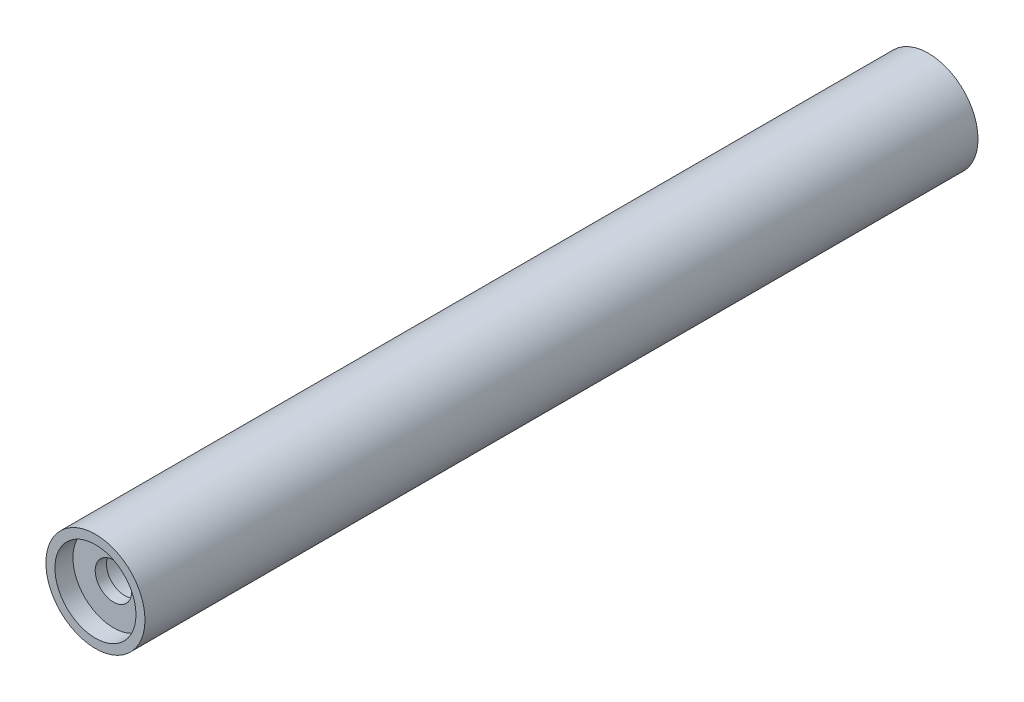
from build123d import *

# Parameters (mm, degrees)
SKETCH1_R           = 5.5
SKETCH1_R_2         = 2.025
BOSS_EXTRUDE1_DEPTH = 92.5
SKETCH2_R           = 4.5
CUT_EXTRUDE1_DEPTH  = 2
SKETCH3_R           = 4.5
CUT_EXTRUDE2_DEPTH  = 2
SKETCH4_R           = 3
CUT_EXTRUDE3_DEPTH  = 43


with BuildPart() as part:
    # Sketch1 → Boss-Extrude1 (new body)
    with BuildSketch(Plane.XY):
        Circle(SKETCH1_R)
        Circle(SKETCH1_R_2, mode=Mode.SUBTRACT)
    extrude(amount=BOSS_EXTRUDE1_DEPTH)

    # Sketch2 → Cut-Extrude1 (cut)
    with BuildSketch(Plane.XY.offset(92.5)):
        Circle(SKETCH2_R)
    extrude(amount=-CUT_EXTRUDE1_DEPTH, mode=Mode.SUBTRACT)

    # Sketch3 → Cut-Extrude2 (cut)
    with BuildSketch(Plane(origin=(0, 0, 0), x_dir=(-1, 0, 0), z_dir=(0, 0, -1))):
        Circle(SKETCH3_R)
    extrude(amount=-CUT_EXTRUDE2_DEPTH, mode=Mode.SUBTRACT)

    # Sketch4 → Cut-Extrude3 (cut, symmetric)
    with BuildSketch(Plane.XY.offset(46.25)):
        Circle(SKETCH4_R)
    extrude(amount=CUT_EXTRUDE3_DEPTH, both=True, mode=Mode.SUBTRACT)


solid = part.part
